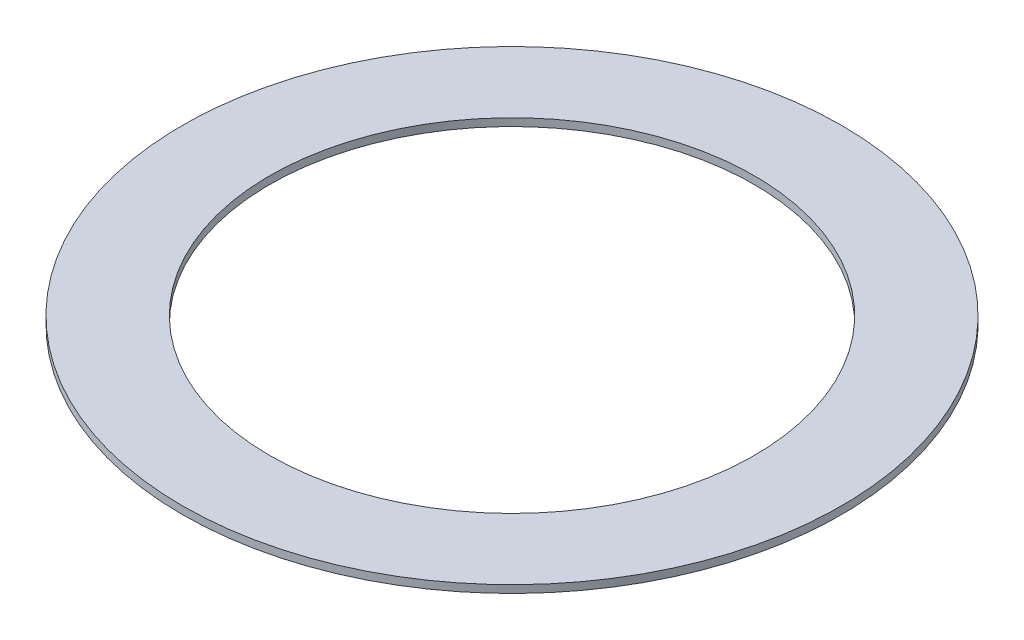
from build123d import *

# Parameters (mm, degrees)
SKETCH1_R           = 103.632
SKETCH1_R_2         = 76.2
BOSS_EXTRUDE1_DEPTH = 2.4


with BuildPart() as part:
    # Sketch1 → Boss-Extrude1 (new body)
    with BuildSketch(Plane(origin=(0, 0, 0), x_dir=(1, 0, 0), z_dir=(0, 1, 0))):
        Circle(SKETCH1_R)
        Circle(SKETCH1_R_2, mode=Mode.SUBTRACT)
    extrude(amount=BOSS_EXTRUDE1_DEPTH)


solid = part.part
